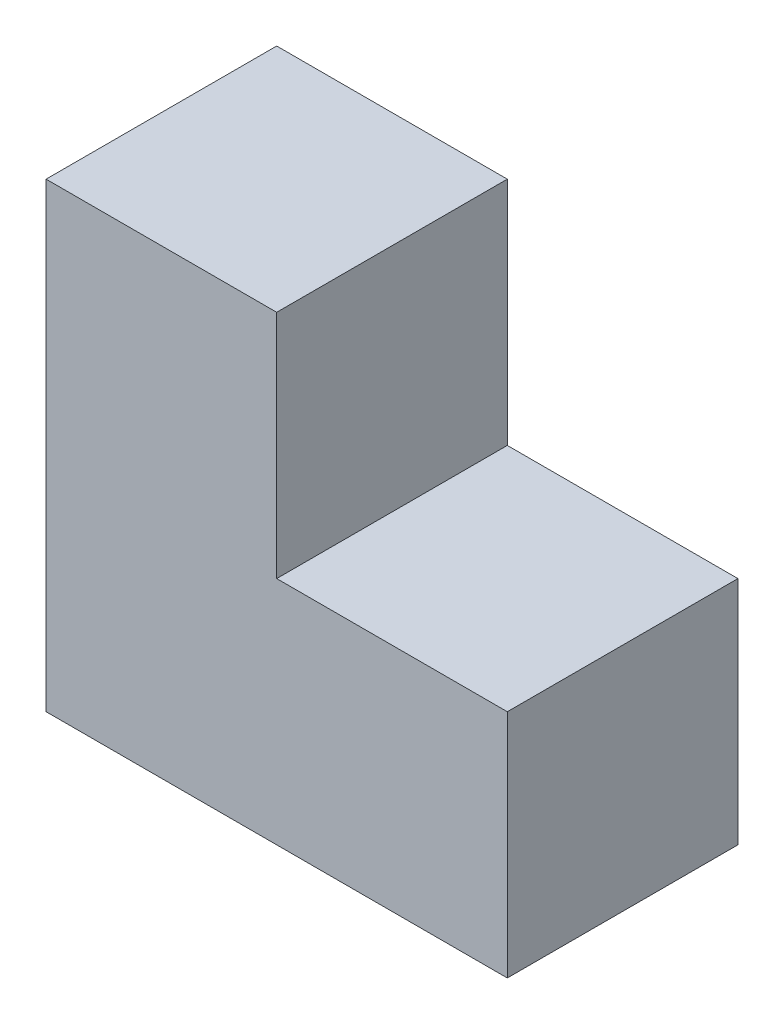
from build123d import *

# Parameters (mm, degrees)
BOSS_EXTRUDE1_DEPTH = 30


with BuildPart() as part:
    # Sketch1 → Boss-Extrude1 (new body)
    with BuildSketch(Plane.XY):
        Polygon((-30, 60), (-30, 0), (30, 0), (30, 30), (0, 30), (0, 60), align=None)
    extrude(amount=-BOSS_EXTRUDE1_DEPTH)


solid = part.part
